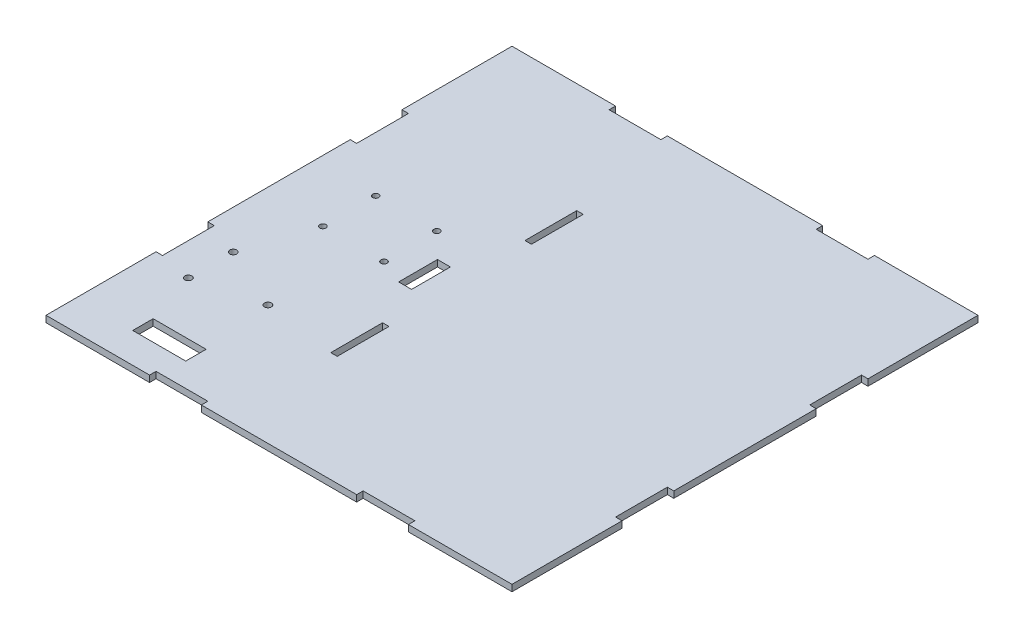
from build123d import *

# Parameters (mm, degrees)
SKETCH1_W           = 228.6
SKETCH1_H           = 228.6
BOSS_EXTRUDE1_DEPTH = 3.175
SKETCH2_R           = 1.7145
SKETCH2_R_2         = 1.5
SKETCH2_W           = 26
SKETCH2_H           = 10.000000066
SKETCH2_W_2         = 6.35
SKETCH2_H_2         = 19.05
CUT_EXTRUDE1_DEPTH  = 4.175
SKETCH3_W           = 3.175
SKETCH3_H           = 25.4
SKETCH3_W_2         = 25.4
SKETCH3_H_2         = 3.175
CUT_EXTRUDE2_DEPTH  = 4.175


with BuildPart() as part:
    # Sketch1 → Boss-Extrude1 (new body)
    with BuildSketch(Plane(origin=(0, 0, 0), x_dir=(1, 0, 0), z_dir=(0, 1, 0))):
        Rectangle(SKETCH1_W, SKETCH1_H)
    extrude(amount=BOSS_EXTRUDE1_DEPTH)

    # Sketch2 → Cut-Extrude1 (cut, through all)
    with BuildSketch(Plane(origin=(0, 3.175, 0), x_dir=(1, 0, 0), z_dir=(0, 1, 0))):
        with Locations((-95.250000001, -63.5)):
            Circle(SKETCH2_R)
        with Locations((-95.25, -41.5)):
            Circle(SKETCH2_R)
        with Locations((-64.250000001, -55.5)):
            Circle(SKETCH2_R)
        with Locations((-84.179457051, 17.330418354)):
            Circle(SKETCH2_R_2)
        with Locations((-54.207457051, 17.330418354)):
            Circle(SKETCH2_R_2)
        with Locations((-54.207457051, -8.577581646)):
            Circle(SKETCH2_R_2)
        with Locations((-84.179457051, -8.577581646)):
            Circle(SKETCH2_R_2)
        with Locations((-73.56649281, -94.479721333)):
            Rectangle(SKETCH2_W, SKETCH2_H)
        with Locations((-38.794244325, -4.118289102)):
            Rectangle(SKETCH2_W_2, SKETCH2_H_2)
    extrude(amount=-CUT_EXTRUDE1_DEPTH, mode=Mode.SUBTRACT)

    # Sketch3 → Cut-Extrude2 (cut, through all)
    with BuildSketch(Plane(origin=(0, 3.175, 0), x_dir=(1, 0, 0), z_dir=(0, 1, 0))):
        with Locations((-112.7125, 47.625)):
            Rectangle(SKETCH3_W, SKETCH3_H)
        with Locations((-112.7125, -47.625)):
            Rectangle(SKETCH3_W, SKETCH3_H)
        with Locations((112.7125, 47.625)):
            Rectangle(SKETCH3_W, SKETCH3_H)
        with Locations((112.7125, -47.625)):
            Rectangle(SKETCH3_W, SKETCH3_H)
        with Locations((50.8, -112.7125)):
            Rectangle(SKETCH3_W_2, SKETCH3_H_2)
        with Locations((-50.8, -112.7125)):
            Rectangle(SKETCH3_W_2, SKETCH3_H_2)
        with Locations((-50.8, 112.7125)):
            Rectangle(SKETCH3_W_2, SKETCH3_H_2)
        with Locations((50.8, 112.7125)):
            Rectangle(SKETCH3_W_2, SKETCH3_H_2)
        with Locations((-26.9875, -47.625)):
            Rectangle(SKETCH3_W, SKETCH3_H)
        with Locations((-26.9875, 47.625)):
            Rectangle(SKETCH3_W, SKETCH3_H)
    extrude(amount=-CUT_EXTRUDE2_DEPTH, mode=Mode.SUBTRACT)


solid = part.part
